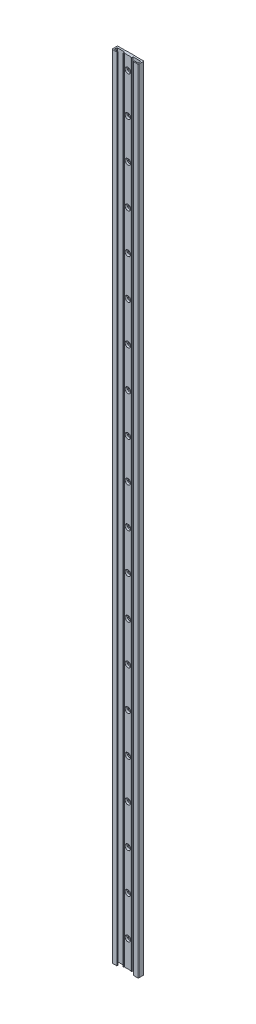
from build123d import *

# Parameters (mm, degrees)
SKETCH1_W                                        = 40
SKETCH1_H                                        = 1200
BOSS_EXTRUDE1_DEPTH                              = 8.7
CUT_EXTRUDE1_DEPTH                               = 1201
SKETCH3_W                                        = 12
SKETCH3_H                                        = 0.2
CUT_EXTRUDE2_DEPTH                               = 1201
SKETCH4_W                                        = 12
SKETCH4_H                                        = 0.2
CUT_EXTRUDE3_DEPTH                               = 1201
DRAFT1_ANGLE                                     = 45
CBORE_FOR_M4_HEX_HEAD_MACHINE_SCREW1_D           = 4.5
CBORE_FOR_M4_HEX_HEAD_MACHINE_SCREW1_DEPTH       = 4.5
CBORE_FOR_M4_HEX_HEAD_MACHINE_SCREW1_CBORE_D     = 8.5
CBORE_FOR_M4_HEX_HEAD_MACHINE_SCREW1_CBORE_DEPTH = 3.1
FILLET1_R                                        = 0.5
FILLET2_R                                        = 1


with BuildPart() as part:
    # Sketch1 → Boss-Extrude1 (new body)
    with BuildSketch(Plane.XY.offset(8.7)):
        with Locations((0, 600)):
            Rectangle(SKETCH1_W, SKETCH1_H)
    extrude(amount=-BOSS_EXTRUDE1_DEPTH)

    # Sketch2 → Cut-Extrude1 (cut, through all)
    with BuildSketch(Plane.XZ):
        Polygon((12.5, 8.7), (-12.5, 8.7), (-12.5, 7.2), (-18, 7.2), (-18, 2.8), (-6.3, 2.8), (-6.3, 5.5), (-4.75, 5.5), (-4.75, 4.5), (4.75, 4.5), (4.75, 5.5), (6.3, 5.5), (6.3, 2.8), (18, 2.8), (18, 7.2), (12.5, 7.2), align=None)
    extrude(amount=-CUT_EXTRUDE1_DEPTH, mode=Mode.SUBTRACT)

    # Sketch3 → Cut-Extrude2 (cut, through all)
    with BuildSketch(Plane.XZ):
        with Locations((14, 0.1)):
            Rectangle(SKETCH3_W, SKETCH3_H)
    extrude(amount=-CUT_EXTRUDE2_DEPTH, mode=Mode.SUBTRACT)

    # Sketch4 → Cut-Extrude3 (cut, through all)
    with BuildSketch(Plane.XZ):
        with Locations((-14, 0.1)):
            Rectangle(SKETCH4_W, SKETCH4_H)
    extrude(amount=-CUT_EXTRUDE3_DEPTH, mode=Mode.SUBTRACT)

    # Draft1
    draft1_faces = [part.faces().sort_by_distance(p)[0] for p in [
        (4.75, 600, 5),
        (-4.75, 600, 5),
    ]]
    draft(draft1_faces, Plane(origin=(-4.75, 1200, 4.5), x_dir=(1, 0, 0), z_dir=(0, 0, 1)), DRAFT1_ANGLE)

    # CBORE for M4 Hex Head Machine Screw1
    with Locations(Plane.XY.offset(4.5)):
        with Locations((0, 160), (0, 100), (0, 40), (0, 220), (0, 280), (0, 340), (0, 400), (0, 460), (0, 520), (0, 580), (0, 640), (0, 700), (0, 760), (0, 820), (0, 880), (0, 940), (0, 1000), (0, 1060), (0, 1120), (0, 1180)):
            CounterBoreHole(CBORE_FOR_M4_HEX_HEAD_MACHINE_SCREW1_D / 2, CBORE_FOR_M4_HEX_HEAD_MACHINE_SCREW1_CBORE_D / 2, CBORE_FOR_M4_HEX_HEAD_MACHINE_SCREW1_CBORE_DEPTH, depth=CBORE_FOR_M4_HEX_HEAD_MACHINE_SCREW1_DEPTH)

    # Fillet1
    fillet1_edges = [part.edges().sort_by_distance(p)[0] for p in [
        (18, 600, 7.2),
        (18, 600, 2.8),
        (-18, 600, 2.8),
        (-18, 600, 7.2),
        (20, 600, 0.2),
        (-20, 600, 0.2),
    ]]
    fillet(fillet1_edges, radius=FILLET1_R)

    # Fillet2
    fillet2_edges = [part.edges().sort_by_distance(p)[0] for p in [
        (20, 600, 8.7),
        (-20, 600, 8.7),
    ]]
    fillet(fillet2_edges, radius=FILLET2_R)


solid = part.part
